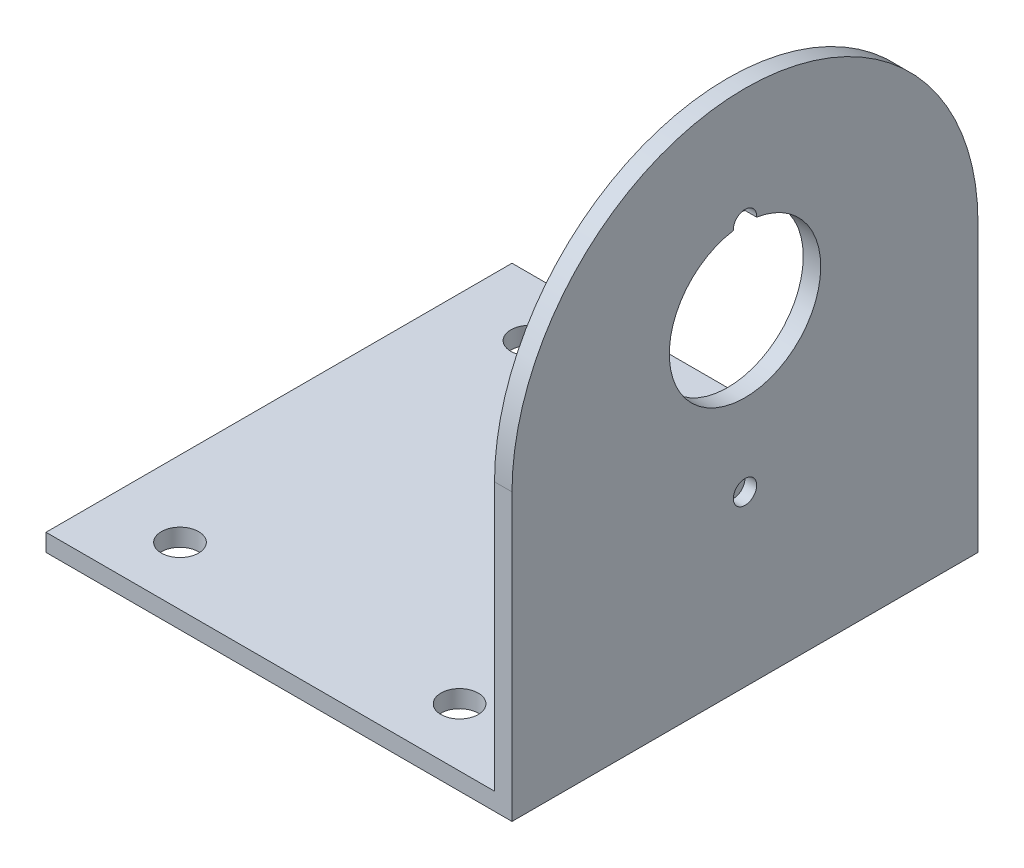
from build123d import *

# Parameters (mm, degrees)
SKETCH_1_W          = 40
SKETCH_1_H          = 40
EXTRUDE_1_DEPTH     = 1.5
EXTRUDE_2_DEPTH     = 1.5
SKETCH_4_R          = 1.6
CUT_EXTRUDE_1_DEPTH = 45.5
SKETCH_6_R          = 6.5
CUT_EXTRUDE_2_DEPTH = 41
SKETCH_7_R          = 1
CUT_EXTRUDE_3_DEPTH = 1


with BuildPart() as part:
    # 草图1 → 凸台-拉伸1 (new body)
    with BuildSketch(Plane(origin=(0, 0, 0), x_dir=(1, 0, 0), z_dir=(0, 1, 0))):
        with Locations((-5, -7.5)):
            Rectangle(SKETCH_1_W, SKETCH_1_H)
    extrude(amount=EXTRUDE_1_DEPTH)

    # 草图3 → 凸台-拉伸2 (add)
    with BuildSketch(Plane(origin=(15, 0, 0), x_dir=(0, 0, -1), z_dir=(1, 0, 0))):
        with BuildLine():
            Line((-27.5, 1.5), (12.5, 1.5))
            Line((12.5, 1.5), (12.5, 24.5))
            ThreePointArc((12.5, 24.5), (-7.5, 44.5), (-27.5, 24.5))
            Line((-27.5, 24.5), (-27.5, 1.5))
        make_face()
    extrude(amount=-EXTRUDE_2_DEPTH)

    # 草图4 → 切除-拉伸1 (cut, through all)
    with BuildSketch(Plane.XZ):
        with Locations((-18.5, 22.5)):
            Circle(SKETCH_4_R)
        with Locations((-18.5, -7.5)):
            Circle(SKETCH_4_R)
        with Locations((5.5, 22.5)):
            Circle(SKETCH_4_R)
        with Locations((5.5, -7.5)):
            Circle(SKETCH_4_R)
    extrude(amount=-CUT_EXTRUDE_1_DEPTH, mode=Mode.SUBTRACT)

    # 草图6 → 切除-拉伸2 (cut, through all)
    with BuildSketch(Plane(origin=(15, 0, 0), x_dir=(0, 0, -1), z_dir=(1, 0, 0))):
        with Locations((-7.5, 28)):
            Circle(SKETCH_6_R)
    extrude(amount=-CUT_EXTRUDE_2_DEPTH, mode=Mode.SUBTRACT)

    # 草图7 → 切除-拉伸3 (cut)
    with BuildSketch(Plane(origin=(15, 0, 0), x_dir=(0, 0, -1), z_dir=(1, 0, 0))):
        with Locations((-7.5, 14.5)):
            Circle(SKETCH_7_R)
        with Locations((-7.5, 34.5)):
            Circle(SKETCH_7_R)
    extrude(amount=-CUT_EXTRUDE_3_DEPTH, mode=Mode.SUBTRACT)


solid = part.part
